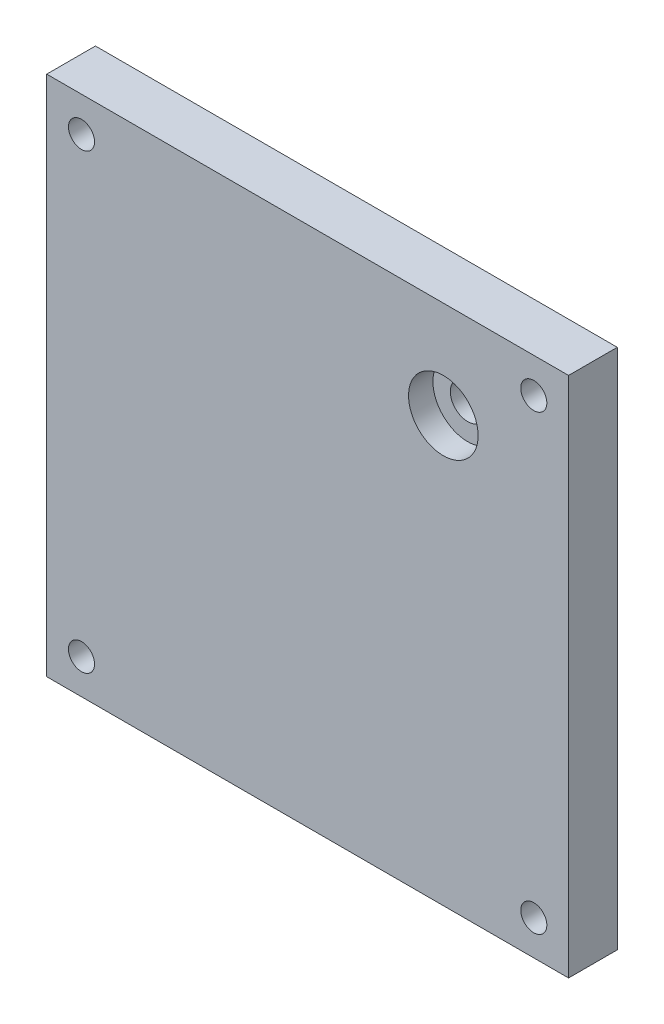
from build123d import *

# Parameters (mm, degrees)
SKETCH1_W           = 95.25
SKETCH1_H           = 95.25
BOSS_EXTRUDE1_DEPTH = 8.89
SKETCH2_OUTSIDE_W   = 124.25
SKETCH2_OUTSIDE_H   = 124.25
SKETCH2_OUTSIDE_W_2 = 95.25
SKETCH2_OUTSIDE_H_2 = 95.25
SKETCH2_OUTSIDE_R   = 2.38125
CUT_EXTRUDE2_DEPTH  = 9.89
SKETCH3_R           = 6.35
CUT_EXTRUDE3_DEPTH  = 4.445
SKETCH4_R           = 3.175
CUT_EXTRUDE4_DEPTH  = 5.445


with BuildPart() as part:
    # Sketch1 → Boss-Extrude1 (new body)
    with BuildSketch(Plane.XY):
        Rectangle(SKETCH1_W, SKETCH1_H)
    extrude(amount=BOSS_EXTRUDE1_DEPTH)

    # Sketch2 outside → Cut-Extrude2 (cut, through all)
    with BuildSketch(Plane.XY.offset(8.89)):
        Rectangle(SKETCH2_OUTSIDE_W, SKETCH2_OUTSIDE_H)
        Rectangle(SKETCH2_OUTSIDE_W_2, SKETCH2_OUTSIDE_H_2, mode=Mode.SUBTRACT)
        with Locations((-41.275, 41.275)):
            Circle(SKETCH2_OUTSIDE_R)
        with Locations((41.275, 41.275)):
            Circle(SKETCH2_OUTSIDE_R)
        with Locations((41.275, -41.275)):
            Circle(SKETCH2_OUTSIDE_R)
        with Locations((-41.275, -41.275)):
            Circle(SKETCH2_OUTSIDE_R)
    extrude(amount=-CUT_EXTRUDE2_DEPTH, mode=Mode.SUBTRACT)

    # Sketch3 → Cut-Extrude3 (cut)
    with BuildSketch(Plane.XY.offset(8.89)):
        with Locations((24.765, 29.845)):
            Circle(SKETCH3_R)
    extrude(amount=-CUT_EXTRUDE3_DEPTH, mode=Mode.SUBTRACT)

    # Sketch4 → Cut-Extrude4 (cut, through all)
    with BuildSketch(Plane.XY.offset(4.445)):
        with Locations((24.765, 29.845)):
            Circle(SKETCH4_R)
    extrude(amount=-CUT_EXTRUDE4_DEPTH, mode=Mode.SUBTRACT)


solid = part.part
